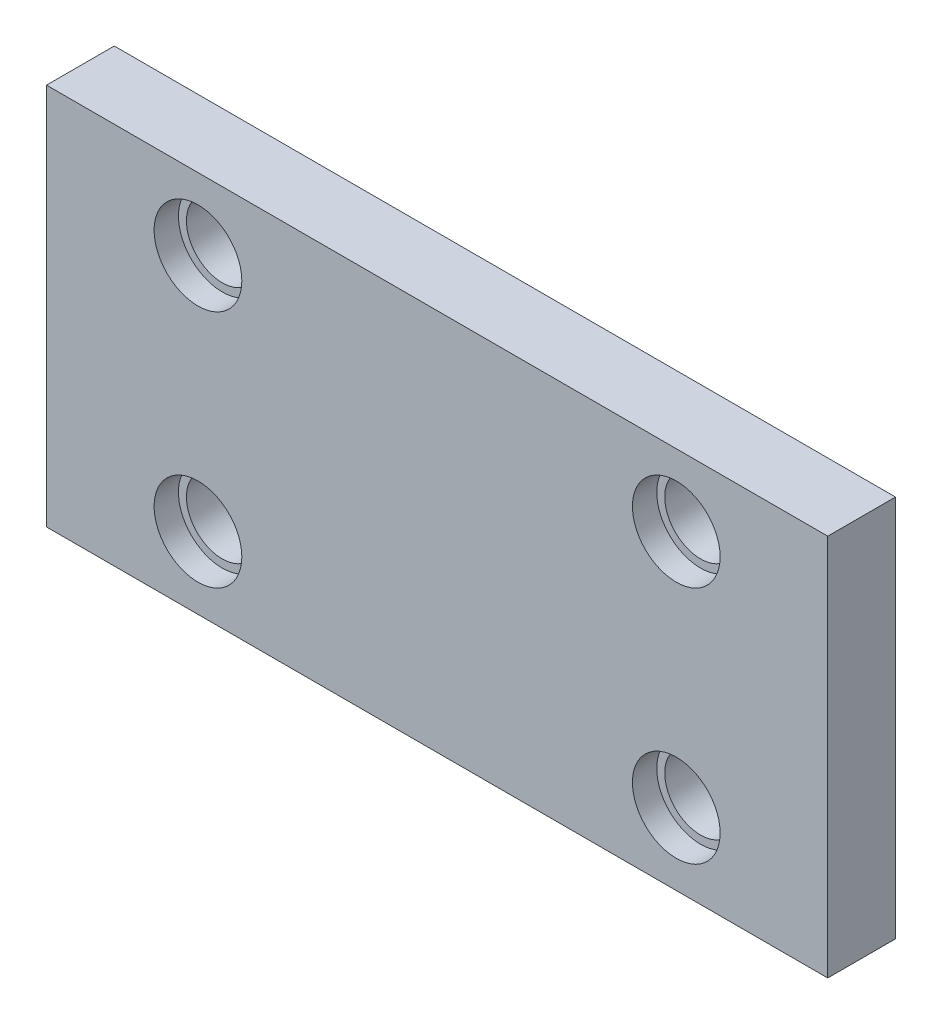
from build123d import *

# Parameters (mm, degrees)
SKETCH1_W                                           = 196
SKETCH1_H                                           = 96
EXTRUDE1_DEPTH                                      = 17
CBORE_FOR_14_MM_LOCATING_GUIDE_BUSHING1_D           = 18
CBORE_FOR_14_MM_LOCATING_GUIDE_BUSHING1_CBORE_D     = 22
CBORE_FOR_14_MM_LOCATING_GUIDE_BUSHING1_CBORE_DEPTH = 6.1


with BuildPart() as part:
    # Sketch1 → Extrude1 (new body)
    with BuildSketch(Plane.XY):
        Rectangle(SKETCH1_W, SKETCH1_H)
    extrude(amount=-EXTRUDE1_DEPTH)

    # CBORE for 14 mm Locating Guide Bushing1 (through all)
    with Locations(Plane(origin=(49.246098405, -1.095802974, 0), x_dir=(-1, 0, 0), z_dir=(0, 0, 1))):
        with Locations((-10.753901595, -31.095802974), (109.246098405, -31.095802974), (109.246098405, 28.904197026), (-10.753901595, 28.904197026)):
            CounterBoreHole(CBORE_FOR_14_MM_LOCATING_GUIDE_BUSHING1_D / 2, CBORE_FOR_14_MM_LOCATING_GUIDE_BUSHING1_CBORE_D / 2, CBORE_FOR_14_MM_LOCATING_GUIDE_BUSHING1_CBORE_DEPTH)


solid = part.part
